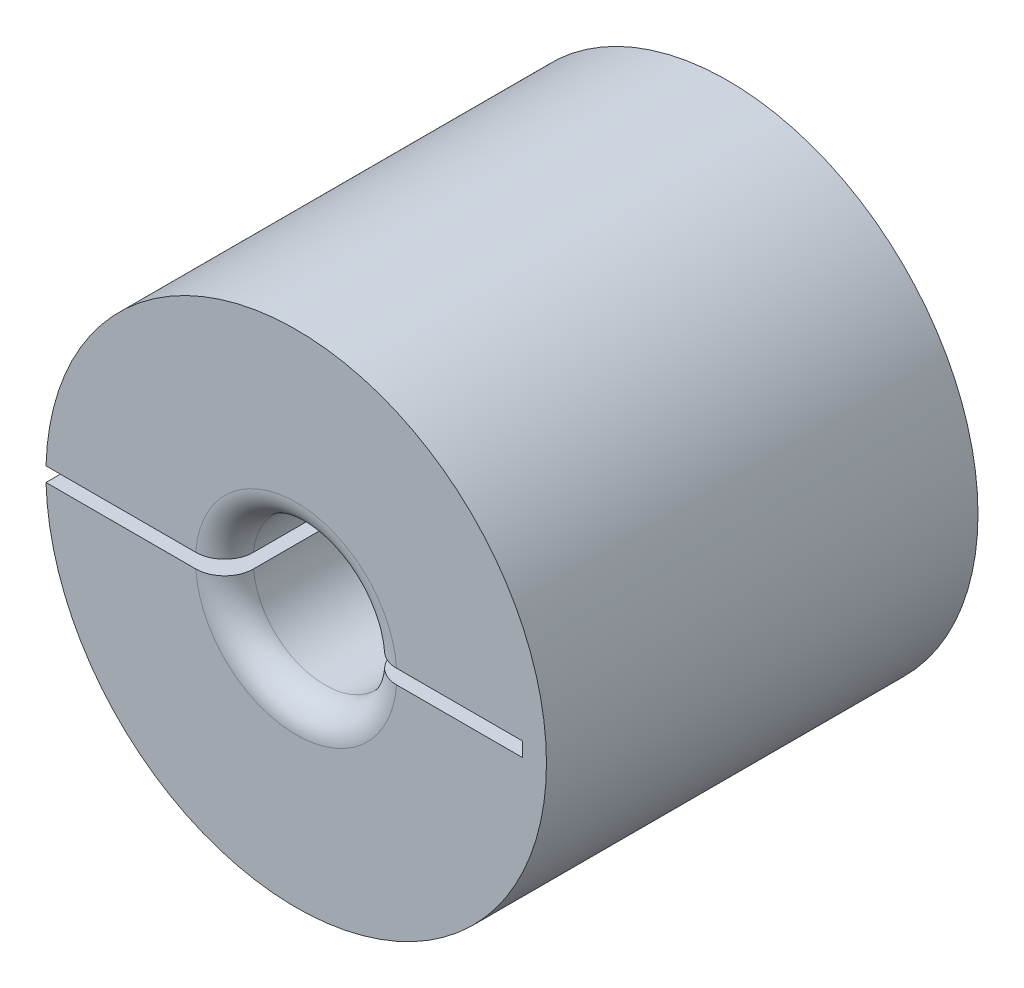
from build123d import *

# Parameters (mm, degrees)
SKETCH1_R           = 11.049
SKETCH1_R_2         = 3.175
BOSS_EXTRUDE1_DEPTH = 19.05
FILLET1_R           = 1.27
SKETCH3_W           = 21.529859436
SKETCH3_H           = 0.635
CUT_EXTRUDE1_DEPTH  = 20.05


with BuildPart() as part:
    # Sketch1 → Boss-Extrude1 (new body)
    with BuildSketch(Plane.XY):
        Circle(SKETCH1_R)
        Circle(SKETCH1_R_2, mode=Mode.SUBTRACT)
    extrude(amount=BOSS_EXTRUDE1_DEPTH)

    # Fillet1
    fillet1_edges = [part.edges().sort_by_distance(p)[0] for p in [
        (-3.175, 0, 0),
        (-3.175, 0, 19.05),
    ]]
    fillet(fillet1_edges, radius=FILLET1_R)

    # Sketch3 → Cut-Extrude1 (cut, through all)
    with BuildSketch(Plane.XY.offset(19.05)):
        with Locations((-0.784069021, 0)):
            Rectangle(SKETCH3_W, SKETCH3_H)
    extrude(amount=-CUT_EXTRUDE1_DEPTH, mode=Mode.SUBTRACT)


solid = part.part
